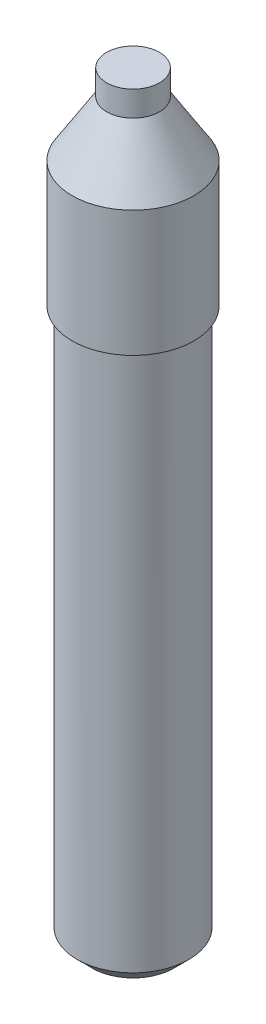
from build123d import *

# Parameters (mm, degrees)
SKETCH4_R          = 7.9375
CUT_EXTRUDE2_DEPTH = 101.6
CHAMFER2_SIZE      = 3


with BuildPart() as part:
    # Sketch3 → Revolve1 (revolve)
    with BuildSketch(Plane.XY):
        Polygon((-11.1125, -151), (-11.1125, -41), (-12.1125, -41), (-12.1125, -16), (-5.25, -5), (-5.25, 0), (0, 0), (0, -151), align=None)
    revolve(axis=Axis((0, -151, 0), (0, 1, 0)))

    # Sketch4 → Cut-Extrude2 (cut)
    with BuildSketch(Plane.XZ.offset(151)):
        Circle(SKETCH4_R)
    extrude(amount=-CUT_EXTRUDE2_DEPTH, mode=Mode.SUBTRACT)

    # Chamfer2
    chamfer2_edges = [part.edges().sort_by_distance(p)[0] for p in [
        (11.1125, -151, 0),
    ]]
    chamfer(chamfer2_edges, length=CHAMFER2_SIZE)


solid = part.part
